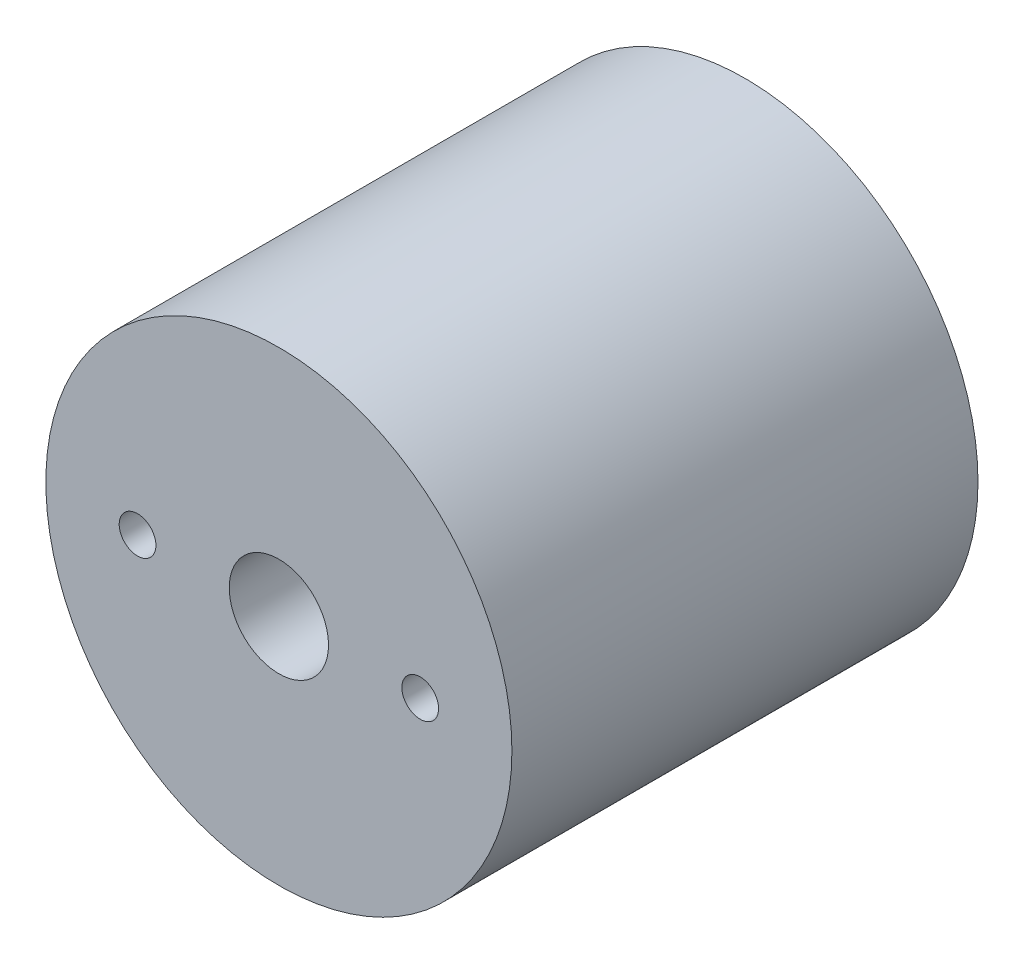
from build123d import *

# Parameters (mm, degrees)
SKETCH1_R               = 12.7
BOSS_EXTRUDE1_DEPTH     = 25.4
SKETCH2_R               = 10.4
CUT_EXTRUDE1_DEPTH      = 5.5
CUT_EXTRUDE2_START      = -1
SKETCH3_R               = 11.75
CUT_EXTRUDE2_DEPTH      = 1.8
F_1_4_28_TAPPED_HOLE1_D = 5.4102
SKETCH11_R              = 1
CUT_EXTRUDE3_DEPTH      = 26.4


with BuildPart() as part:
    # Sketch1 → Boss-Extrude1 (new body)
    with BuildSketch(Plane.XY):
        Circle(SKETCH1_R)
    extrude(amount=BOSS_EXTRUDE1_DEPTH)

    # Sketch2 → Cut-Extrude1 (cut)
    with BuildSketch(Plane(origin=(0, 0, 0), x_dir=(-1, 0, 0), z_dir=(0, 0, -1))):
        Circle(SKETCH2_R)
    extrude(amount=-CUT_EXTRUDE1_DEPTH, mode=Mode.SUBTRACT)

    # Sketch3 → Cut-Extrude2 (cut)
    with BuildSketch(Plane(origin=(0, 0, 0), x_dir=(-1, 0, 0), z_dir=(0, 0, -1)).offset(CUT_EXTRUDE2_START)):
        Circle(SKETCH3_R)
    extrude(amount=-CUT_EXTRUDE2_DEPTH, mode=Mode.SUBTRACT)

    # 1/4-28 Tapped Hole1 (through all)
    with Locations(Plane.XY.offset(25.4)):
        with Locations((0, 0)):
            Hole(F_1_4_28_TAPPED_HOLE1_D / 2)

    # Sketch10 → Cut-Revolve1 (revolve, cut)
    with BuildSketch(Plane(origin=(0, 0, 0), x_dir=(1, 0, 0), z_dir=(0, 1, 0))):
        Polygon((0, -25.402256059), (8.654624222, -5.5), (0, -5.5), align=None)
    revolve(axis=Axis((0, 0, 29.736025406), (0, 0, -1)), mode=Mode.SUBTRACT)

    # Sketch11 → Cut-Extrude3 (cut, through all)
    with BuildSketch(Plane.XY.offset(25.4)):
        with Locations((-7.70255, 0)):
            Circle(SKETCH11_R)
        with Locations((7.70255, 0)):
            Circle(SKETCH11_R)
    extrude(amount=-CUT_EXTRUDE3_DEPTH, mode=Mode.SUBTRACT)


solid = part.part
